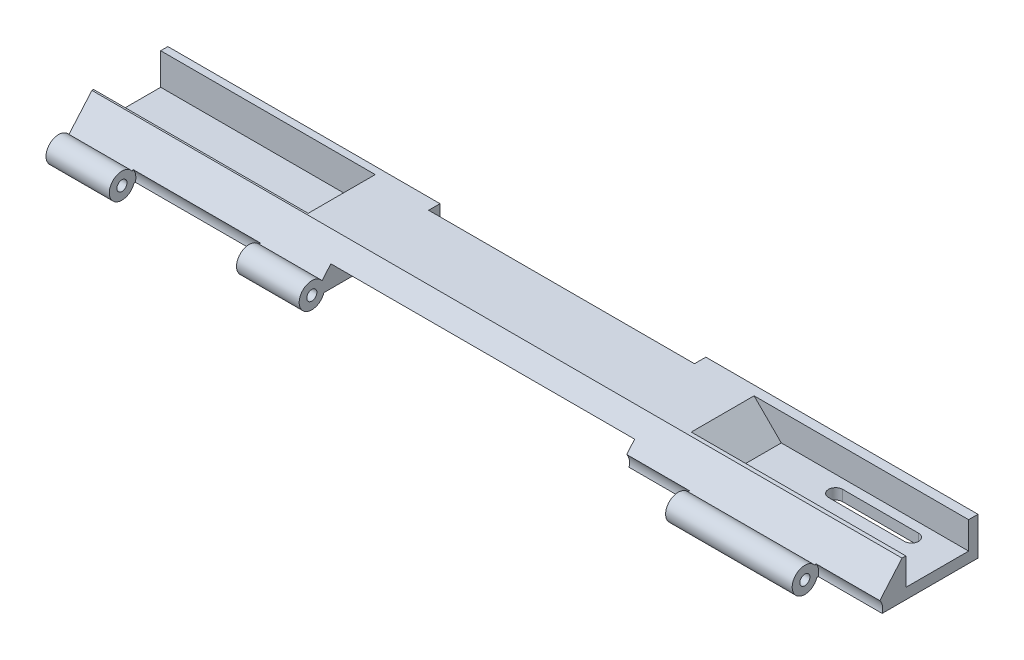
from build123d import *

# Parameters (mm, degrees)
SKETCH1_R                = 1.6002
SKETCH1_R_2              = 0.8128
BOSS_EXTRUDE5_DEPTH      = 162.56
CUT_EXTRUDE1_DEPTH       = 14.351
SKETCH3_W                = 0.889
SKETCH3_H                = 5.842
BOSS_EXTRUDE6_DEPTH      = 36.957
SKETCH16_W               = 13.462
SKETCH16_H               = 6.460130881
BOSS_EXTRUDE7_DEPTH      = 33.02
CUT_EXTRUDE4_DEPTH       = 15.24
SKETCH18_W               = 1.778
SKETCH18_H               = 5.842
BOSS_EXTRUDE8_DEPTH      = 38.1
CUT_EXTRUDE5_DEPTH       = 14.224
SKETCH20_W               = 2.1336
SKETCH20_H               = 5.461
BOSS_EXTRUDE9_DEPTH      = 36.322
SKETCH22_R               = 1.4224
CUT_EXTRUDE7_DEPTH       = 20.32
CUT_EXTRUDE7_DEPTH_BACK  = 24.13
SKETCH25_W               = 112.268
SKETCH25_H               = 3.007323321
CUT_EXTRUDE8_DEPTH       = 24.13
SKETCH27_R               = 1.778
CUT_EXTRUDE9_DEPTH       = 112.268
CUT_EXTRUDE12_DEPTH      = 14.224
SKETCH34_W               = 43.053
SKETCH34_H               = 2.1336
BOSS_EXTRUDE14_DEPTH     = 7.112
SKETCH35_R               = 1.4224
CUT_EXTRUDE13_DEPTH      = 7.112
SKETCH37_W               = 60.96
SKETCH37_H               = 15.24
CUT_EXTRUDE14_DEPTH      = 3.048
SKETCH38_R               = 0.8128
CUT_EXTRUDE15_DEPTH      = 5.08
SKETCH39_R               = 0.8128
CUT_EXTRUDE16_DEPTH      = 5.08
SKETCH40_W               = 60.96
SKETCH40_H               = 2.54
CUT_EXTRUDE17_DEPTH      = 3.048
SKETCH41_R               = 1.161307013
BOSS_EXTRUDE15_DEPTH     = 6.604
SKETCH42_R               = 1.020818471
BOSS_EXTRUDE16_DEPTH     = 5.588
SKETCH43_R               = 0.8128
CUT_EXTRUDE18_DEPTH      = 5.08
SKETCH44_R               = 0.8128
CUT_EXTRUDE19_DEPTH      = 5.08
SKETCH46_W               = 60.96
SKETCH46_H               = 9.087986699
CUT_EXTRUDE21_DEPTH      = 3.048
SKETCH47_W               = 53.34
SKETCH47_H               = 2.286
CUT_EXTRUDE22_DEPTH      = 15.24
SKETCH48_R               = 2.54
BOSS_EXTRUDE17_DEPTH     = 25.146
SKETCH49_R               = 2.54
BOSS_EXTRUDE18_DEPTH     = 25.146
SKETCH50_R               = 2.794
CUT_EXTRUDE23_DEPTH      = 112.268
SKETCH51_R               = 1.27
CUT_EXTRUDE24_DEPTH      = 174.498
CUT_EXTRUDE25_DEPTH      = 1.27
SKETCH55_W               = 46.703523857
SKETCH55_H               = 5.873481267
CUT_EXTRUDE26_DEPTH      = 9.144
CUT_EXTRUDE26_DEPTH_BACK = 8.636
SKETCH57_R               = 1.029255476
BOSS_EXTRUDE20_DEPTH     = 5.08
SKETCH58_R               = 1.09273592
BOSS_EXTRUDE21_DEPTH     = 7.112
SKETCH59_R               = 1.016
CUT_EXTRUDE27_DEPTH      = 66.04
CUT_EXTRUDE27_DEPTH_BACK = 5.08
SKETCH60_R               = 1.869467668
SKETCH60_R_2             = 1.016
BOSS_EXTRUDE22_DEPTH     = 162.56
SKETCH61_R               = 2.219373527
CUT_EXTRUDE28_DEPTH      = 112.268
SKETCH62_R               = 1.016
BOSS_EXTRUDE26_DEPTH     = 25.654
SKETCH65_R               = 1.016
BOSS_EXTRUDE27_DEPTH     = 25.654
SKETCH67_R               = 2.794
CUT_EXTRUDE32_DEPTH      = 12.827
SKETCH68_R               = 2.794
CUT_EXTRUDE33_DEPTH      = 12.827
SKETCH72_R               = 2.794
CUT_EXTRUDE34_DEPTH      = 25.654
BOSS_EXTRUDE28_DEPTH     = 0.127
SKETCH77_R               = 1.016
BOSS_EXTRUDE29_DEPTH     = 0.254
SKETCH79_R               = 1.016
CUT_EXTRUDE35_DEPTH      = 15.748
SKETCH87_W               = 23.622
SKETCH87_H               = 13.462
BOSS_EXTRUDE30_DEPTH     = 6.096
CUT_EXTRUDE36_DEPTH      = 14.9098
SKETCH89_W               = 1.4478
SKETCH89_H               = 6.35
BOSS_EXTRUDE31_DEPTH     = 30.6578
BOSS_EXTRUDE32_DEPTH     = 2.159
BOSS_EXTRUDE33_DEPTH     = 2.159
CUT_EXTRUDE38_DEPTH      = 43.053
BOSS_EXTRUDE35_DEPTH     = 14.859
SKETCH98_W               = 13.462
SKETCH98_H               = 6.35
CUT_EXTRUDE41_DEPTH      = 19.431
BOSS_EXTRUDE36_DEPTH     = 15.113
SKETCH102_W              = 13.462
SKETCH102_H              = 6.35
CUT_EXTRUDE42_DEPTH      = 27.051
BOSS_EXTRUDE39_DEPTH     = 2.159
BOSS_EXTRUDE40_DEPTH     = 14.986
BOSS_EXTRUDE41_DEPTH     = 2.159


with BuildPart() as part:
    # Sketch1 → Boss-Extrude5 (new body)
    with BuildSketch(Plane(origin=(0, 0, 0), x_dir=(0, 0, -1), z_dir=(1, 0, 0))):
        with BuildLine():
            ThreePointArc((11.4584801, -1.874600251), (11.409460099, -2.267640517), (11.265403421, -2.636600251))
            Line((11.265403421, -2.636600251), (11.4584801, -2.636600251))
            Line((11.4584801, -2.636600251), (31.7784801, -2.636600251))
            Line((31.7784801, -2.636600251), (31.7784801, 4.983399749))
            Line((31.7784801, 4.983399749), (16.5384801, 4.983399749))
            Line((16.5384801, 4.983399749), (11.265403421, -1.112600251))
            ThreePointArc((11.265403421, -1.112600251), (11.409460099, -1.481559985), (11.4584801, -1.874600251))
        make_face()
        with Locations((9.8582801, -1.874600251)):
            Circle(SKETCH1_R)
        with Locations((9.8582801, -1.874600251)):
            Circle(SKETCH1_R_2, mode=Mode.SUBTRACT)
    extrude(amount=BOSS_EXTRUDE5_DEPTH)

    # Sketch2 → Cut-Extrude1 (cut)
    with BuildSketch(Plane(origin=(0, 0, -31.7784801), x_dir=(-1, 0, 0), z_dir=(0, 0, -1))):
        Polygon((0, 4.983399749), (0, -0.858600251), (-17.78, -0.858600251), (-23.622, 4.983399749), align=None)
    extrude(amount=-CUT_EXTRUDE1_DEPTH, mode=Mode.SUBTRACT)

    # Sketch3 → Boss-Extrude6 (add)
    with BuildSketch(Plane.ZY):
        with Locations((-31.3339801, 2.062399749)):
            Rectangle(SKETCH3_W, SKETCH3_H)
    extrude(amount=-BOSS_EXTRUDE6_DEPTH)

    # Sketch16 → Boss-Extrude7 (add)
    with BuildSketch(Plane.ZY):
        with Locations((-24.1584801, 1.753334308)):
            Rectangle(SKETCH16_W, SKETCH16_H)
    extrude(amount=-BOSS_EXTRUDE7_DEPTH)

    # Sketch17 → Cut-Extrude4 (cut)
    with BuildSketch(Plane(origin=(0, 0, -31.7784801), x_dir=(-1, 0, 0), z_dir=(0, 0, -1))):
        Polygon((0, 4.983399749), (0, -0.858600251), (-17.78, -0.858600251), (-23.622, 4.983399749), align=None)
    extrude(amount=-CUT_EXTRUDE4_DEPTH, mode=Mode.SUBTRACT)

    # Sketch18 → Boss-Extrude8 (add)
    with BuildSketch(Plane.ZY):
        with Locations((-30.8894801, 2.062399749)):
            Rectangle(SKETCH18_W, SKETCH18_H)
    extrude(amount=-BOSS_EXTRUDE8_DEPTH)

    # Sketch19 → Cut-Extrude5 (cut)
    with BuildSketch(Plane(origin=(0, 0, -31.7784801), x_dir=(-1, 0, 0), z_dir=(0, 0, -1))):
        Polygon((-162.56, 4.983399749), (-162.56, -0.477600251), (-142.24, -0.477600251), (-136.779, 4.983399749), align=None)
    extrude(amount=-CUT_EXTRUDE5_DEPTH, mode=Mode.SUBTRACT)

    # Sketch20 → Boss-Extrude9 (add)
    with BuildSketch(Plane(origin=(162.56, 0, 0), x_dir=(0, 0, -1), z_dir=(1, 0, 0))):
        with Locations((30.7116801, 2.252899749)):
            Rectangle(SKETCH20_W, SKETCH20_H)
    extrude(amount=-BOSS_EXTRUDE9_DEPTH)

    # Sketch22 → Cut-Extrude7 (cut, two sides)
    with BuildSketch(Plane(origin=(0, -0.477600251, 0), x_dir=(1, 0, 0), z_dir=(0, 1, 0))) as cut_extrude7_sk:
        with Locations((145.9484, 26.5714801)):
            Circle(SKETCH22_R)
        with BuildLine():
            ThreePointArc((147.3708, 26.5714801), (146.954188686, 25.565691415), (145.9484, 25.1490801))
            Line((145.9484, 25.1490801), (157.217057139, 25.1490801))
            ThreePointArc((157.217057139, 25.1490801), (155.794657139, 26.5714801), (157.217057139, 27.9938801))
            Line((157.217057139, 27.9938801), (145.9484, 27.9938801))
            ThreePointArc((145.9484, 27.9938801), (146.954188686, 27.577268786), (147.3708, 26.5714801))
        make_face()
        with Locations((157.217057139, 26.5714801)):
            Circle(SKETCH22_R)
        with BuildLine():
            ThreePointArc((157.217057139, 19.1292801), (155.794657139, 20.5516801), (157.217057139, 21.9740801))
            Line((157.217057139, 21.9740801), (145.9484, 21.9740801))
            ThreePointArc((145.9484, 21.9740801), (146.954188686, 21.557468786), (147.3708, 20.5516801))
            ThreePointArc((147.3708, 20.5516801), (146.954188686, 19.545891415), (145.9484, 19.1292801))
            Line((145.9484, 19.1292801), (157.217057139, 19.1292801))
        make_face()
        with Locations((157.217057139, 20.5516801)):
            Circle(SKETCH22_R)
        with Locations((145.9484, 20.5516801)):
            Circle(SKETCH22_R)
    extrude(amount=CUT_EXTRUDE7_DEPTH, mode=Mode.SUBTRACT)
    extrude(cut_extrude7_sk.sketch, amount=-CUT_EXTRUDE7_DEPTH_BACK, mode=Mode.SUBTRACT)

    # Sketch25 → Cut-Extrude8 (cut)
    with BuildSketch(Plane(origin=(0, 4.983399749, 0), x_dir=(1, 0, 0), z_dir=(0, 1, 0))):
        with Locations((81.28, 9.761741761)):
            Rectangle(SKETCH25_W, SKETCH25_H)
    extrude(amount=-CUT_EXTRUDE8_DEPTH, mode=Mode.SUBTRACT)

    # Sketch27 → Cut-Extrude9 (cut)
    with BuildSketch(Plane.ZY.offset(-137.414)):
        with Locations((-9.8582801, -1.874600251)):
            Circle(SKETCH27_R)
    extrude(amount=CUT_EXTRUDE9_DEPTH, mode=Mode.SUBTRACT)

    # Sketch31 → Cut-Extrude12 (cut)
    with BuildSketch(Plane(origin=(0, 0, -31.7784801), x_dir=(-1, 0, 0), z_dir=(0, 0, -1))):
        Polygon((-162.56, 4.983399749), (-162.56, -0.477600251), (-124.968, -0.477600251), (-119.507, 4.983399749), (-124.079, 4.983399749), align=None)
    extrude(amount=-CUT_EXTRUDE12_DEPTH, mode=Mode.SUBTRACT)

    # Sketch34 → Boss-Extrude14 (add)
    with BuildSketch(Plane(origin=(0, 4.983399749, 0), x_dir=(1, 0, 0), z_dir=(0, 1, 0))):
        with Locations((141.0335, 30.7116801)):
            Rectangle(SKETCH34_W, SKETCH34_H)
    extrude(amount=-BOSS_EXTRUDE14_DEPTH)

    # Sketch35 → Cut-Extrude13 (cut)
    with BuildSketch(Plane(origin=(0, -0.477600251, 0), x_dir=(1, 0, 0), z_dir=(0, 1, 0))):
        with BuildLine():
            Line((130.048, 25.1490801), (145.9484, 25.1490801))
            ThreePointArc((145.9484, 25.1490801), (144.526, 26.5714801), (145.9484, 27.9938801))
            Line((145.9484, 27.9938801), (130.048, 27.9938801))
            ThreePointArc((130.048, 27.9938801), (131.053788686, 27.577268786), (131.4704, 26.5714801))
            ThreePointArc((131.4704, 26.5714801), (131.053788686, 25.565691415), (130.048, 25.1490801))
        make_face()
        with BuildLine():
            ThreePointArc((145.9484, 19.1292801), (144.526, 20.5516801), (145.9484, 21.9740801))
            Line((145.9484, 21.9740801), (130.048, 21.9740801))
            ThreePointArc((130.048, 21.9740801), (131.053788686, 21.557468786), (131.4704, 20.5516801))
            ThreePointArc((131.4704, 20.5516801), (131.053788686, 19.545891415), (130.048, 19.1292801))
            Line((130.048, 19.1292801), (145.9484, 19.1292801))
        make_face()
        with Locations((130.048, 20.5516801)):
            Circle(SKETCH35_R)
        with Locations((130.048, 26.5714801)):
            Circle(SKETCH35_R)
    extrude(amount=-CUT_EXTRUDE13_DEPTH, mode=Mode.SUBTRACT)

    # Sketch37 → Cut-Extrude14 (cut)
    with BuildSketch(Plane(origin=(0, -2.636600251, 0), x_dir=(-1, 0, 0), z_dir=(0, -1, 0))):
        with Locations((-81.28, 21.6184801)):
            Rectangle(SKETCH37_W, SKETCH37_H)
    extrude(amount=-CUT_EXTRUDE14_DEPTH, mode=Mode.SUBTRACT)

    # Sketch38 → Cut-Extrude15 (cut)
    with BuildSketch(Plane.ZY.offset(-111.76)):
        with Locations((-27.9684801, -1.112600251)):
            Circle(SKETCH38_R)
    extrude(amount=-CUT_EXTRUDE15_DEPTH, mode=Mode.SUBTRACT)

    # Sketch39 → Cut-Extrude16 (cut)
    with BuildSketch(Plane(origin=(50.8, 0, 0), x_dir=(0, 0, -1), z_dir=(1, 0, 0))):
        with Locations(Location((27.9684801, -1.112600251, 0), (0, 0, 180))):
            Circle(SKETCH39_R)
    extrude(amount=-CUT_EXTRUDE16_DEPTH, mode=Mode.SUBTRACT)

    # Sketch40 → Cut-Extrude17 (cut)
    with BuildSketch(Plane(origin=(0, -2.636600251, 0), x_dir=(-1, 0, 0), z_dir=(0, -1, 0))):
        with Locations((-81.28, 30.5084801)):
            Rectangle(SKETCH40_W, SKETCH40_H)
    extrude(amount=-CUT_EXTRUDE17_DEPTH, mode=Mode.SUBTRACT)

    # Sketch41 → Boss-Extrude15 (add)
    with BuildSketch(Plane(origin=(50.8, 0, 0), x_dir=(0, 0, -1), z_dir=(1, 0, 0))):
        with Locations((27.9684801, -1.112600251)):
            Circle(SKETCH41_R)
    extrude(amount=-BOSS_EXTRUDE15_DEPTH)

    # Sketch42 → Boss-Extrude16 (add)
    with BuildSketch(Plane.ZY.offset(-111.76)):
        with Locations((-27.9684801, -1.112600251)):
            Circle(SKETCH42_R)
    extrude(amount=-BOSS_EXTRUDE16_DEPTH)

    # Sketch43 → Cut-Extrude18 (cut)
    with BuildSketch(Plane(origin=(50.8, 0, 0), x_dir=(0, 0, -1), z_dir=(1, 0, 0))):
        with Locations((30.5084801, -1.112600251)):
            Circle(SKETCH43_R)
    extrude(amount=-CUT_EXTRUDE18_DEPTH, mode=Mode.SUBTRACT)

    # Sketch44 → Cut-Extrude19 (cut)
    with BuildSketch(Plane.ZY.offset(-111.76)):
        with Locations(Location((-30.5084801, -1.112600251, 0), (0, 0, 180))):
            Circle(SKETCH44_R)
    extrude(amount=-CUT_EXTRUDE19_DEPTH, mode=Mode.SUBTRACT)

    # Sketch46 → Cut-Extrude21 (cut)
    with BuildSketch(Plane(origin=(0, -2.636600251, 0), x_dir=(-1, 0, 0), z_dir=(0, -1, 0))):
        with Locations((-81.28, 9.45448675)):
            Rectangle(SKETCH46_W, SKETCH46_H)
    extrude(amount=-CUT_EXTRUDE21_DEPTH, mode=Mode.SUBTRACT)

    # Sketch47 → Cut-Extrude22 (cut)
    with BuildSketch(Plane(origin=(0, 0.411399749, 0), x_dir=(-1, 0, 0), z_dir=(0, -1, 0))):
        with Locations((-81.28, 30.6354801)):
            Rectangle(SKETCH47_W, SKETCH47_H)
    extrude(amount=-CUT_EXTRUDE22_DEPTH, mode=Mode.SUBTRACT)

    # Sketch48 → Boss-Extrude17 (add)
    with BuildSketch(Plane.ZY):
        with Locations((-9.8582801, -1.874600251)):
            Circle(SKETCH48_R)
    extrude(amount=-BOSS_EXTRUDE17_DEPTH)

    # Sketch49 → Boss-Extrude18 (add)
    with BuildSketch(Plane(origin=(162.56, 0, 0), x_dir=(0, 0, -1), z_dir=(1, 0, 0))):
        with Locations((9.8582801, -1.874600251)):
            Circle(SKETCH49_R)
    extrude(amount=-BOSS_EXTRUDE18_DEPTH)

    # Sketch50 → Cut-Extrude23 (cut)
    with BuildSketch(Plane.ZY.offset(-137.414)):
        with Locations((-9.8582801, -1.874600251)):
            Circle(SKETCH50_R)
    extrude(amount=CUT_EXTRUDE23_DEPTH, mode=Mode.SUBTRACT)

    # Sketch51 → Cut-Extrude24 (cut)
    with BuildSketch(Plane(origin=(162.56, 0, 0), x_dir=(0, 0, -1), z_dir=(1, 0, 0))):
        with Locations((9.8582801, -1.874600251)):
            Circle(SKETCH51_R)
    extrude(amount=-CUT_EXTRUDE24_DEPTH, mode=Mode.SUBTRACT)

    # Sketch52 → Cut-Extrude25 (cut)
    with BuildSketch(Plane(origin=(0, 0.411399749, 0), x_dir=(-1, 0, 0), z_dir=(0, -1, 0))):
        Polygon((-50.8, 31.7784801), (-50.8, 12.546363432), (-111.76, 12.6522801), (-111.76, 31.7784801), align=None)
    extrude(amount=-CUT_EXTRUDE25_DEPTH, mode=Mode.SUBTRACT)

    # Sketch55 → Cut-Extrude26 (cut, two sides)
    with BuildSketch(Plane.XZ.offset(2.636600251)) as cut_extrude26_sk:
        with Locations((88.408238071, -10.745489599)):
            Rectangle(SKETCH55_W, SKETCH55_H)
    extrude(amount=CUT_EXTRUDE26_DEPTH, mode=Mode.SUBTRACT)
    extrude(cut_extrude26_sk.sketch, amount=-CUT_EXTRUDE26_DEPTH_BACK, mode=Mode.SUBTRACT)

    # Sketch57 → Boss-Extrude20 (add)
    with BuildSketch(Plane(origin=(45.72, 0, 0), x_dir=(0, 0, -1), z_dir=(1, 0, 0))):
        with Locations((30.5084801, -1.112600251)):
            Circle(SKETCH57_R)
    extrude(amount=BOSS_EXTRUDE20_DEPTH)

    # Sketch58 → Boss-Extrude21 (add)
    with BuildSketch(Plane.ZY.offset(-111.76)):
        with Locations((-30.5084801, -1.112600251)):
            Circle(SKETCH58_R)
    extrude(amount=-BOSS_EXTRUDE21_DEPTH)

    # Sketch59 → Cut-Extrude27 (cut, two sides)
    with BuildSketch(Plane(origin=(50.8, 0, 0), x_dir=(0, 0, -1), z_dir=(1, 0, 0))) as cut_extrude27_sk:
        with Locations((29.2384801, -0.477600251)):
            Circle(SKETCH59_R)
    extrude(amount=CUT_EXTRUDE27_DEPTH, mode=Mode.SUBTRACT)
    extrude(cut_extrude27_sk.sketch, amount=-CUT_EXTRUDE27_DEPTH_BACK, mode=Mode.SUBTRACT)

    # Sketch60 → Boss-Extrude22 (add)
    with BuildSketch(Plane.ZY):
        with Locations((-9.8582801, -1.874600251)):
            Circle(SKETCH60_R)
        with Locations((-9.8582801, -1.874600251)):
            Circle(SKETCH60_R_2, mode=Mode.SUBTRACT)
    extrude(amount=-BOSS_EXTRUDE22_DEPTH)

    # Sketch61 → Cut-Extrude28 (cut)
    with BuildSketch(Plane.ZY.offset(-137.414)):
        with Locations((-9.8582801, -1.874600251)):
            Circle(SKETCH61_R)
    extrude(amount=CUT_EXTRUDE28_DEPTH, mode=Mode.SUBTRACT)

    # Sketch62 → Boss-Extrude26 (add)
    with BuildSketch(Plane(origin=(25.146, 0, 0), x_dir=(0, 0, -1), z_dir=(1, 0, 0))):
        with BuildLine():
            Line((12.07614536, -0.175332853), (11.906096413, -0.371919863))
            ThreePointArc((11.906096413, -0.371919863), (12.272100043, -1.083984489), (12.3982801, -1.874600251))
            ThreePointArc((12.3982801, -1.874600251), (12.368861124, -2.260064807), (12.281285672, -2.636600251))
            Line((12.281285672, -2.636600251), (12.546363432, -2.636600251))
            ThreePointArc((12.546363432, -2.636600251), (12.602645637, -1.350297092), (12.07614536, -0.175332853))
        make_face()
        with BuildLine():
            ThreePointArc((12.3982801, -1.874600251), (12.272100043, -1.083984489), (11.906096413, -0.371919863))
            ThreePointArc((11.906096413, -0.371919863), (7.352435653, -2.289743123), (12.281285672, -2.636600251))
            ThreePointArc((12.281285672, -2.636600251), (12.368861124, -2.260064807), (12.3982801, -1.874600251))
        make_face()
        with Locations(Location((9.8582801, -1.874600251, 0), (0, 0, 180))):
            Circle(SKETCH62_R, mode=Mode.SUBTRACT)
    extrude(amount=BOSS_EXTRUDE26_DEPTH)

    # Sketch65 → Boss-Extrude27 (add)
    with BuildSketch(Plane.ZY.offset(-137.414)):
        with BuildLine():
            ThreePointArc((-12.281285672, -2.636600251), (-12.364124548, -1.459457379), (-11.906096413, -0.371919863))
            Line((-11.906096413, -0.371919863), (-12.07614536, -0.175332853))
            ThreePointArc((-12.07614536, -0.175332853), (-12.602645637, -1.350297092), (-12.546363432, -2.636600251))
            Line((-12.546363432, -2.636600251), (-12.281285672, -2.636600251))
        make_face()
        with BuildLine():
            ThreePointArc((-7.3182801, -1.874600251), (-9.067664339, 0.539219692), (-11.906096413, -0.371919863))
            ThreePointArc((-11.906096413, -0.371919863), (-12.364124548, -1.459457379), (-12.281285672, -2.636600251))
            ThreePointArc((-12.281285672, -2.636600251), (-9.472815544, -4.385181275), (-7.3182801, -1.874600251))
        make_face()
        with Locations((-9.8582801, -1.874600251)):
            Circle(SKETCH65_R, mode=Mode.SUBTRACT)
    extrude(amount=BOSS_EXTRUDE27_DEPTH)

    # Sketch67 → Cut-Extrude32 (cut)
    with BuildSketch(Plane(origin=(162.56, 0, 0), x_dir=(0, 0, -1), z_dir=(1, 0, 0))):
        with Locations((9.8582801, -1.874600251)):
            Circle(SKETCH67_R)
    extrude(amount=-CUT_EXTRUDE32_DEPTH, mode=Mode.SUBTRACT)

    # Sketch68 → Cut-Extrude33 (cut)
    with BuildSketch(Plane.ZY.offset(-111.76)):
        with Locations((-9.8582801, -1.874600251)):
            Circle(SKETCH68_R)
    extrude(amount=-CUT_EXTRUDE33_DEPTH, mode=Mode.SUBTRACT)

    # Sketch72 → Cut-Extrude34 (cut)
    with BuildSketch(Plane.ZY.offset(-12.573)):
        with Locations((-9.8582801, -1.874600251)):
            Circle(SKETCH72_R)
    extrude(amount=-CUT_EXTRUDE34_DEPTH, mode=Mode.SUBTRACT)

    # Sketch74 → Boss-Extrude28 (add)
    with BuildSketch(Plane.ZY.offset(-12.573)):
        with BuildLine():
            Line((-12.546363432, -2.636600251), (-12.281285672, -2.636600251))
            ThreePointArc((-12.281285672, -2.636600251), (-7.352435653, -2.289743123), (-11.906096413, -0.371919863))
            Line((-11.906096413, -0.371919863), (-12.07614536, -0.175332853))
            ThreePointArc((-12.07614536, -0.175332853), (-12.602645637, -1.350297092), (-12.546363432, -2.636600251))
        make_face()
    extrude(amount=-BOSS_EXTRUDE28_DEPTH)

    # Sketch77 → Boss-Extrude29 (add)
    with BuildSketch(Plane.ZY.offset(-124.587)):
        with BuildLine():
            ThreePointArc((-11.906096413, -0.371919863), (-12.364124548, -1.459457379), (-12.281285672, -2.636600251))
            ThreePointArc((-12.281285672, -2.636600251), (-9.472815544, -4.385181275), (-7.3182801, -1.874600251))
            ThreePointArc((-7.3182801, -1.874600251), (-9.067664339, 0.539219692), (-11.906096413, -0.371919863))
        make_face()
        with Locations((-9.8582801, -1.874600251)):
            Circle(SKETCH77_R, mode=Mode.SUBTRACT)
        with BuildLine():
            Line((-12.546363432, -2.636600251), (-12.281285672, -2.636600251))
            ThreePointArc((-12.281285672, -2.636600251), (-12.364124548, -1.459457379), (-11.906096413, -0.371919863))
            Line((-11.906096413, -0.371919863), (-12.07614536, -0.175332853))
            ThreePointArc((-12.07614536, -0.175332853), (-12.602645637, -1.350297092), (-12.546363432, -2.636600251))
        make_face()
    extrude(amount=BOSS_EXTRUDE29_DEPTH)

    # Sketch79 → Cut-Extrude35 (cut)
    with BuildSketch(Plane.ZY):
        with Locations((-9.8582801, -1.874600251)):
            Circle(SKETCH79_R)
    extrude(amount=-CUT_EXTRUDE35_DEPTH, mode=Mode.SUBTRACT)

    # Sketch87 → Boss-Extrude30 (add)
    with BuildSketch(Plane(origin=(0, 4.983399749, 0), x_dir=(1, 0, 0), z_dir=(0, 1, 0))):
        with Locations((11.811, 23.2694801)):
            Rectangle(SKETCH87_W, SKETCH87_H)
    extrude(amount=-BOSS_EXTRUDE30_DEPTH)

    # Sketch88 → Cut-Extrude36 (cut)
    with BuildSketch(Plane(origin=(0, 0, -31.7784801), x_dir=(-1, 0, 0), z_dir=(0, 0, -1))):
        Polygon((0, 4.983399749), (0, -1.366600251), (-17.78, -1.366600251), (-23.622, 4.983399749), align=None)
    extrude(amount=-CUT_EXTRUDE36_DEPTH, mode=Mode.SUBTRACT)

    # Sketch89 → Boss-Extrude31 (add)
    with BuildSketch(Plane.ZY):
        with Locations((-31.0545801, 1.808399749)):
            Rectangle(SKETCH89_W, SKETCH89_H)
    extrude(amount=-BOSS_EXTRUDE31_DEPTH)

    # Sketch90 → Boss-Extrude32 (add)
    with BuildSketch(Plane(origin=(0, -2.636600251, 0), x_dir=(-1, 0, 0), z_dir=(0, -1, 0))):
        with BuildLine():
            Line((-130.048, 27.9938801), (-137.16, 27.9938801))
            ThreePointArc((-137.16, 27.9938801), (-136.154211314, 27.577268786), (-135.7376, 26.5714801))
            ThreePointArc((-135.7376, 26.5714801), (-136.154211314, 25.565691415), (-137.16, 25.1490801))
            Line((-137.16, 25.1490801), (-130.048, 25.1490801))
            ThreePointArc((-130.048, 25.1490801), (-128.6256, 26.5714801), (-130.048, 27.9938801))
        make_face()
        with BuildLine():
            ThreePointArc((-135.7376, 20.5516801), (-136.154211314, 19.545891415), (-137.16, 19.1292801))
            Line((-137.16, 19.1292801), (-130.048, 19.1292801))
            ThreePointArc((-130.048, 19.1292801), (-128.6256, 20.5516801), (-130.048, 21.9740801))
            Line((-130.048, 21.9740801), (-137.16, 21.9740801))
            ThreePointArc((-137.16, 21.9740801), (-136.154211314, 21.557468786), (-135.7376, 20.5516801))
        make_face()
    extrude(amount=-BOSS_EXTRUDE32_DEPTH)

    # Sketch91 → Boss-Extrude33 (add)
    with BuildSketch(Plane(origin=(0, -2.636600251, 0), x_dir=(-1, 0, 0), z_dir=(0, -1, 0))):
        with BuildLine():
            Line((-156.251857139, 26.5714801), (-158.639457139, 26.5714801))
            ThreePointArc((-158.639457139, 26.5714801), (-158.222845825, 25.565691415), (-157.217057139, 25.1490801))
            Line((-157.217057139, 25.1490801), (-154.829457139, 25.1490801))
            ThreePointArc((-154.829457139, 25.1490801), (-155.835245825, 25.565691415), (-156.251857139, 26.5714801))
        make_face()
        with BuildLine():
            ThreePointArc((-157.217057139, 27.9938801), (-158.222845825, 27.577268786), (-158.639457139, 26.5714801))
            Line((-158.639457139, 26.5714801), (-156.251857139, 26.5714801))
            ThreePointArc((-156.251857139, 26.5714801), (-155.835245825, 27.577268786), (-154.829457139, 27.9938801))
            Line((-154.829457139, 27.9938801), (-157.217057139, 27.9938801))
        make_face()
        with BuildLine():
            ThreePointArc((-157.217057139, 21.9740801), (-158.222845825, 21.557468786), (-158.639457139, 20.5516801))
            Line((-158.639457139, 20.5516801), (-156.251857139, 20.5516801))
            ThreePointArc((-156.251857139, 20.5516801), (-155.835245825, 21.557468786), (-154.829457139, 21.9740801))
            Line((-154.829457139, 21.9740801), (-157.217057139, 21.9740801))
        make_face()
        with BuildLine():
            Line((-156.251857139, 20.5516801), (-158.639457139, 20.5516801))
            ThreePointArc((-158.639457139, 20.5516801), (-158.222845825, 19.545891415), (-157.217057139, 19.1292801))
            Line((-157.217057139, 19.1292801), (-154.829457139, 19.1292801))
            ThreePointArc((-154.829457139, 19.1292801), (-155.835245825, 19.545891415), (-156.251857139, 20.5516801))
        make_face()
    extrude(amount=-BOSS_EXTRUDE33_DEPTH)

    # Sketch92 → Cut-Extrude38 (cut)
    with BuildSketch(Plane(origin=(162.56, 0, 0), x_dir=(0, 0, -1), z_dir=(1, 0, 0))):
        Polygon((29.6448801, -0.477600251), (29.8988801, -0.477600251), (29.8988801, 4.983399749), (17.3004801, 4.983399749), (17.3004801, -0.477600251), align=None)
    extrude(amount=-CUT_EXTRUDE38_DEPTH, mode=Mode.SUBTRACT)

    # Sketch94 → Boss-Extrude35 (add)
    with BuildSketch(Plane(origin=(0, 0, -31.7784801), x_dir=(-1, 0, 0), z_dir=(0, 0, -1))):
        Polygon((-119.507, 4.983399749), (-124.968, -0.477600251), (-119.507, -0.477600251), align=None)
    extrude(amount=-BOSS_EXTRUDE35_DEPTH)

    # Sketch98 → Cut-Extrude41 (cut)
    with BuildSketch(Plane.ZY.offset(-23.622)):
        with Locations((-23.5996801, 1.808399749)):
            Rectangle(SKETCH98_W, SKETCH98_H)
    extrude(amount=-CUT_EXTRUDE41_DEPTH, mode=Mode.SUBTRACT)

    # Sketch101 → Boss-Extrude36 (add)
    with BuildSketch(Plane(origin=(0, 0, -31.7784801), x_dir=(-1, 0, 0), z_dir=(0, 0, -1))):
        Polygon((-43.053, 4.983399749), (-37.592, -0.477600251), (-43.053, -0.477600251), align=None)
    extrude(amount=-BOSS_EXTRUDE36_DEPTH)

    # Sketch102 → Cut-Extrude42 (cut)
    with BuildSketch(Plane.ZY):
        with Locations((-23.5996801, 1.808399749)):
            Rectangle(SKETCH102_W, SKETCH102_H)
    extrude(amount=-CUT_EXTRUDE42_DEPTH, mode=Mode.SUBTRACT)

    # Sketch103 → Boss-Extrude39 (add)
    with BuildSketch(Plane(origin=(0, -0.477600251, 0), x_dir=(1, 0, 0), z_dir=(0, 1, 0))):
        with BuildLine():
            ThreePointArc((137.7696, 26.5714801), (138.186211314, 27.577268786), (139.192, 27.9938801))
            Line((139.192, 27.9938801), (137.16, 27.9938801))
            ThreePointArc((137.16, 27.9938801), (135.7376, 26.5714801), (137.16, 25.1490801))
            Line((137.16, 25.1490801), (139.192, 25.1490801))
            ThreePointArc((139.192, 25.1490801), (138.186211314, 25.565691415), (137.7696, 26.5714801))
        make_face()
        with BuildLine():
            ThreePointArc((137.7696, 20.5516801), (138.186211314, 21.557468786), (139.192, 21.9740801))
            Line((139.192, 21.9740801), (137.16, 21.9740801))
            ThreePointArc((137.16, 21.9740801), (135.7376, 20.5516801), (137.16, 19.1292801))
            Line((137.16, 19.1292801), (139.192, 19.1292801))
            ThreePointArc((139.192, 19.1292801), (138.186211314, 19.545891415), (137.7696, 20.5516801))
        make_face()
    extrude(amount=-BOSS_EXTRUDE39_DEPTH)

    # Sketch105 → Boss-Extrude40 (add)
    with BuildSketch(Plane(origin=(0, 0, -31.7784801), x_dir=(-1, 0, 0), z_dir=(0, 0, -1))):
        Polygon((-43.053, 4.983399749), (-43.053, -2.200805148), (-35.868795103, -2.200805148), align=None)
    extrude(amount=-BOSS_EXTRUDE40_DEPTH)

    # Sketch106 → Boss-Extrude41 (add)
    with BuildSketch(Plane(origin=(0, -0.477600251, 0), x_dir=(1, 0, 0), z_dir=(0, 1, 0))):
        with BuildLine():
            ThreePointArc((154.432, 27.9938801), (155.437788686, 27.577268786), (155.8544, 26.5714801))
            ThreePointArc((155.8544, 26.5714801), (155.437788686, 25.565691415), (154.432, 25.1490801))
            Line((154.432, 25.1490801), (154.829457139, 25.1490801))
            ThreePointArc((154.829457139, 25.1490801), (156.251857139, 26.5714801), (154.829457139, 27.9938801))
            Line((154.829457139, 27.9938801), (154.432, 27.9938801))
        make_face()
        with BuildLine():
            ThreePointArc((154.432, 21.9740801), (155.437788686, 21.557468786), (155.8544, 20.5516801))
            ThreePointArc((155.8544, 20.5516801), (155.437788686, 19.545891415), (154.432, 19.1292801))
            Line((154.432, 19.1292801), (154.829457139, 19.1292801))
            ThreePointArc((154.829457139, 19.1292801), (156.251857139, 20.5516801), (154.829457139, 21.9740801))
            Line((154.829457139, 21.9740801), (154.432, 21.9740801))
        make_face()
    extrude(amount=-BOSS_EXTRUDE41_DEPTH)


solid = part.part
